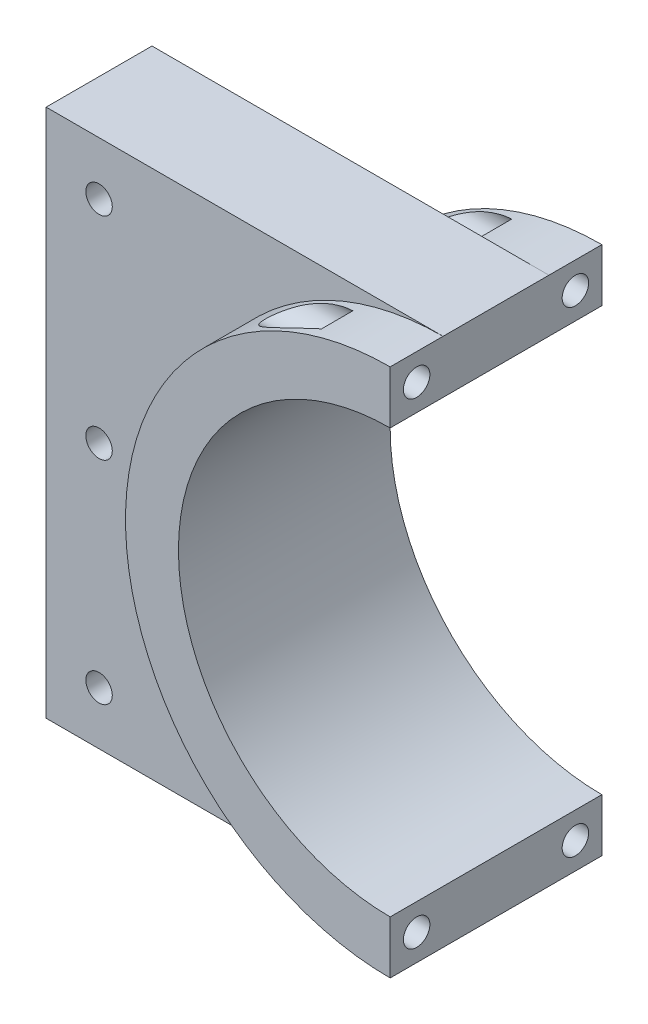
from build123d import *

# Parameters (mm, degrees)
SKETCH1_W           = 25.4
SKETCH1_H           = 127
SKETCH1_R           = 3.175
BOSS_EXTRUDE1_DEPTH = 25.4
BOSS_EXTRUDE2_DEPTH = 25.4
BOSS_EXTRUDE3_DEPTH = 12.7
BOSS_EXTRUDE4_DEPTH = 12.7
SKETCH5_R           = 3.175
CUT_EXTRUDE1_DEPTH  = 96.25
SKETCH6_R           = 5.08
CUT_EXTRUDE2_DEPTH  = 76.2


with BuildPart() as part:
    # Sketch1 → Boss-Extrude1 (new body)
    with BuildSketch(Plane.XY):
        Rectangle(SKETCH1_W, SKETCH1_H)
        with Locations((0, 50.732762061)):
            Circle(SKETCH1_R, mode=Mode.SUBTRACT)
        Circle(SKETCH1_R, mode=Mode.SUBTRACT)
        with Locations((0, -50.8)):
            Circle(SKETCH1_R, mode=Mode.SUBTRACT)
    extrude(amount=BOSS_EXTRUDE1_DEPTH)

    # Sketch2 → Boss-Extrude2 (add)
    with BuildSketch(Plane.XY.offset(25.4)):
        with BuildLine():
            Line((12.7, 63.5), (12.7, -63.5))
            Line((12.7, -63.5), (82.55, -63.5))
            Line((82.55, -63.5), (82.55, -50.8))
            ThreePointArc((82.55, -50.8), (31.75, 0), (82.55, 50.8))
            Line((82.55, 50.8), (82.55, 63.5))
            Line((82.55, 63.5), (12.7, 63.5))
        make_face()
    extrude(amount=-BOSS_EXTRUDE2_DEPTH)

    # Sketch3 → Boss-Extrude3 (add)
    with BuildSketch(Plane.XY.offset(25.4)):
        with BuildLine():
            Line((82.55, 63.5), (82.55, 50.8))
            ThreePointArc((82.55, 50.8), (31.75, 0), (82.55, -50.8))
            Line((82.55, -50.8), (82.55, -63.5))
            ThreePointArc((82.55, -63.5), (19.05, 0), (82.55, 63.5))
        make_face()
    extrude(amount=BOSS_EXTRUDE3_DEPTH)

    # Sketch4 → Boss-Extrude4 (add)
    with BuildSketch(Plane(origin=(0, 0, 0), x_dir=(-1, 0, 0), z_dir=(0, 0, -1))):
        with BuildLine():
            Line((-82.55, 63.5), (-82.55, 50.8))
            ThreePointArc((-82.55, 50.8), (-31.75, 0), (-82.55, -50.8))
            Line((-82.55, -50.8), (-82.55, -63.5))
            ThreePointArc((-82.55, -63.5), (-19.05, 0), (-82.55, 63.5))
        make_face()
    extrude(amount=BOSS_EXTRUDE4_DEPTH)

    # Sketch5 → Cut-Extrude1 (cut, through all)
    with BuildSketch(Plane(origin=(82.55, 0, 0), x_dir=(0, 0, -1), z_dir=(1, 0, 0))):
        with Locations((-31.75, 57.15)):
            Circle(SKETCH5_R)
        with Locations((6.35, 57.15)):
            Circle(SKETCH5_R)
        with Locations((6.35, -57.15)):
            Circle(SKETCH5_R)
        with Locations((-31.75, -57.15)):
            Circle(SKETCH5_R)
    extrude(amount=-CUT_EXTRUDE1_DEPTH, mode=Mode.SUBTRACT)

    # Sketch6 → Cut-Extrude2 (cut)
    with BuildSketch(Plane.ZY.offset(12.7)):
        with Locations((-6.35, 57.15)):
            Circle(SKETCH6_R)
        with Locations((31.75, 57.15)):
            Circle(SKETCH6_R)
        with Locations((31.75, -57.15)):
            Circle(SKETCH6_R)
        with Locations((-6.35, -57.15)):
            Circle(SKETCH6_R)
    extrude(amount=-CUT_EXTRUDE2_DEPTH, mode=Mode.SUBTRACT)


solid = part.part
